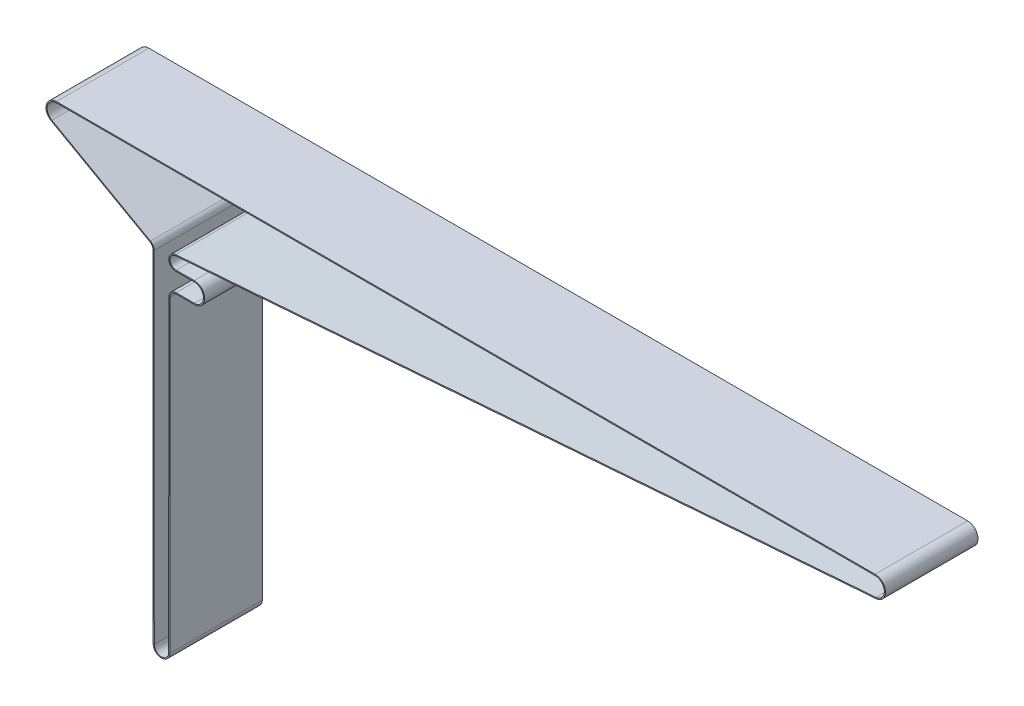
from build123d import *

# Parameters (mm, degrees)
EXTRUDE_THIN1_DEPTH = 63.5


with BuildPart() as part:
    # Sketch1 → Extrude-Thin1 (new body, symmetric)
    with BuildSketch(Plane.XY):
        with BuildLine():
            Line((-959.66739225, -104.081924367), (-934.763425273, -103.976128348))
            ThreePointArc((-934.763425273, -103.976128348), (-920.479, -118.2), (-934.763425273, -132.423871652))
            Line((-934.763425273, -132.423871652), (-959.66739225, -132.318075633))
            ThreePointArc((-959.66739225, -132.318075633), (-965.616046993, -134.759141539), (-968.084999173, -140.696276466))
            Line((-968.084999173, -140.696276466), (-968.273001128, -563.905077546))
            ThreePointArc((-968.273001128, -563.905077546), (-979.703244004, -575.329999997), (-991.132999079, -563.904589538))
            Line((-991.132999079, -563.904589538), (-991.321000676, -95.696634339))
            ThreePointArc((-991.321000676, -95.696634339), (-992.470278455, -91.463767823), (-995.600017332, -88.39086481))
            Line((-995.600017332, -88.39086481), (-1130.965637255, -12.403380928))
            ThreePointArc((-1130.965637255, -12.403380928), (-1137.764320182, 3.59836669), (-1124.003, 14.224))
            Line((-1124.003, 14.224), (0, 14.224))
            ThreePointArc((0, 14.224), (14.213745369, 0.540017203), (1.079255768, -14.182996263))
            Line((1.079255768, -14.182996263), (-960.338990006, -87.342162917))
            ThreePointArc((-960.338990006, -87.342162917), (-968.078262268, -96.036014785), (-959.66739225, -104.081924367))
        make_face()
        with BuildLine():
            Line((-959.660918114, -105.605910615), (-934.756951136, -105.500114596))
            ThreePointArc((-934.756951136, -105.500114596), (-922.003, -118.2), (-934.756951136, -130.899885404))
            Line((-934.756951136, -130.899885404), (-959.660918114, -130.794089385))
            ThreePointArc((-959.660918114, -130.794089385), (-966.691146447, -133.678985455), (-969.608999023, -140.69559946))
            Line((-969.608999023, -140.69559946), (-969.797000977, -563.90440054))
            ThreePointArc((-969.797000977, -563.90440054), (-979.70321147, -573.805999998), (-989.608999201, -563.903977599))
            Line((-989.608999201, -563.903977599), (-989.797000799, -95.696022401))
            ThreePointArc((-989.797000799, -95.696022401), (-991.155238175, -90.693543791), (-994.854020483, -87.061931139))
            Line((-994.854020483, -87.061931139), (-1130.219640407, -11.074447257))
            ThreePointArc((-1130.219640407, -11.074447257), (-1136.28989302, 3.212827402), (-1124.003, 12.7))
            Line((-1124.003, 12.7), (0, 12.7))
            ThreePointArc((0, 12.7), (12.69084408, 0.482158217), (0.963621221, -12.66338952))
            Line((0.963621221, -12.66338952), (-960.454624553, -85.822556174))
            ThreePointArc((-960.454624553, -85.822556174), (-969.601037226, -96.097108382), (-959.660918114, -105.605910615))
        make_face(mode=Mode.SUBTRACT)
    extrude(amount=EXTRUDE_THIN1_DEPTH, both=True)


solid = part.part
